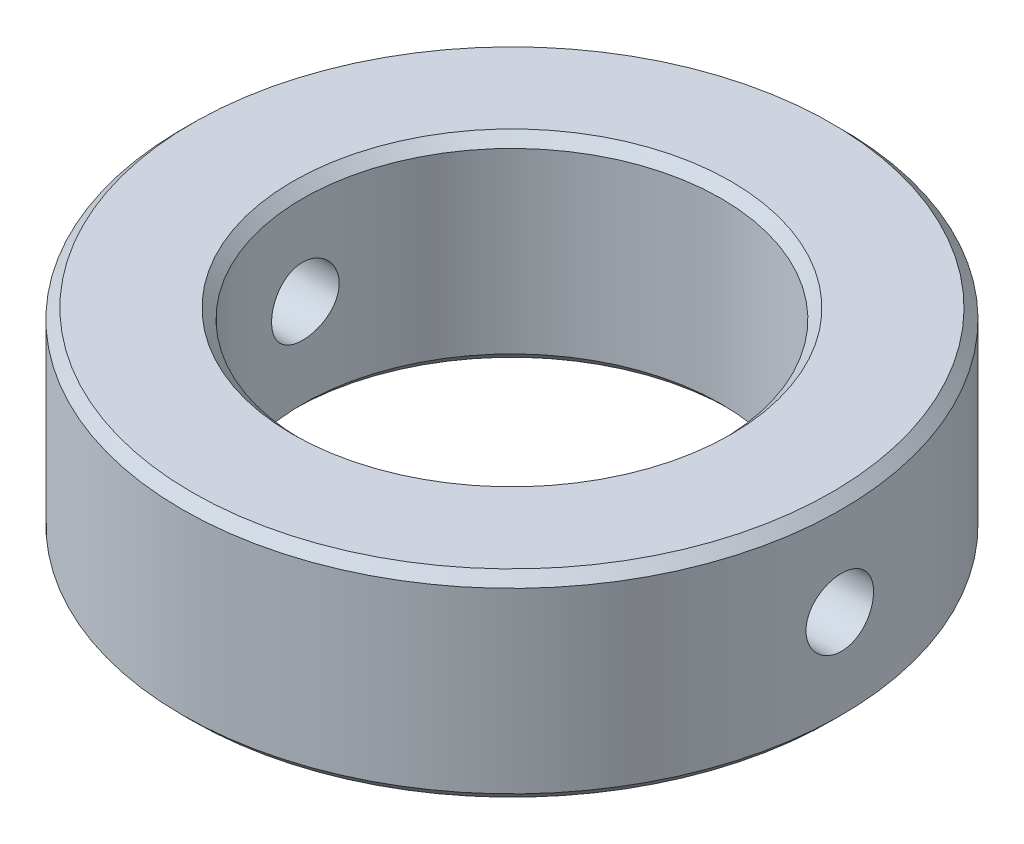
from build123d import *

# Parameters (mm, degrees)
SKETCH1_R                = 10
SKETCH1_R_2              = 6.35
BOSS_EXTRUDE1_DEPTH      = 6
M2_5X0_45_TAPPED_HOLE1_D = 2.05
CHAMFER1_SIZE            = 0.3


with BuildPart() as part:
    # Sketch1 → Boss-Extrude1 (new body)
    with BuildSketch(Plane(origin=(0, 0, 0), x_dir=(1, 0, 0), z_dir=(0, 1, 0))):
        Circle(SKETCH1_R)
        Circle(SKETCH1_R_2, mode=Mode.SUBTRACT)
    extrude(amount=BOSS_EXTRUDE1_DEPTH)

    # M2.5x0.45 Tapped Hole1 (through all)
    with Locations(Plane(origin=(10, 0, 0), x_dir=(0, 0, -1), z_dir=(1, 0, 0))):
        with Locations((0, 3)):
            Hole(M2_5X0_45_TAPPED_HOLE1_D / 2)

    # Chamfer1
    chamfer1_edges = [part.edges().sort_by_distance(p)[0] for p in [
        (-10, 0, 0),
        (-10, 6, 0),
        (-6.35, 0, 0),
        (-6.35, 6, 0),
    ]]
    chamfer(chamfer1_edges, length=CHAMFER1_SIZE)


solid = part.part
